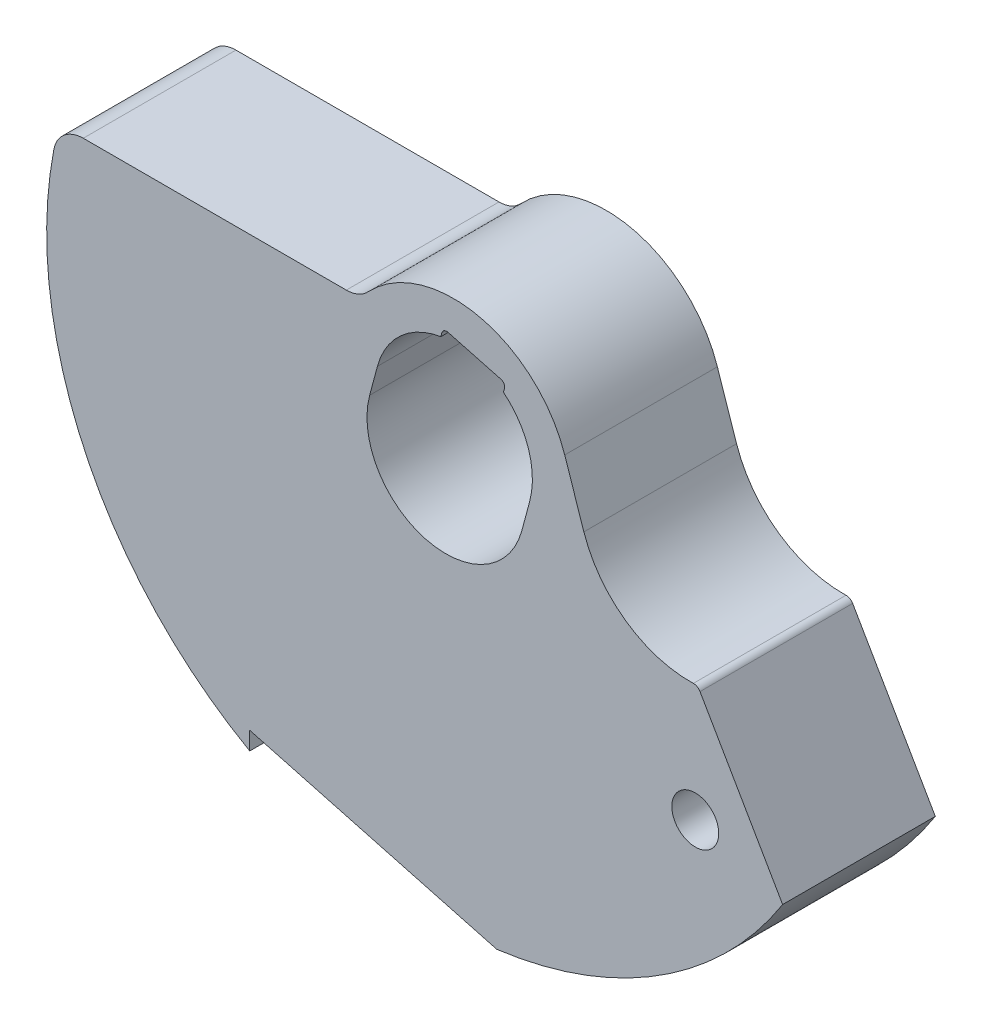
from build123d import *

# Parameters (mm, degrees)
SKETCH1_R           = 1.1938
BOSS_EXTRUDE1_DEPTH = 7.7724


with BuildPart() as part:
    # Sketch1 → Boss-Extrude1 (new body)
    with BuildSketch(Plane.XY):
        with BuildLine():
            Line((-5.065262452, 5.08), (-18.456556559, 5.08))
            ThreePointArc((-18.456556559, 5.08), (-19.426909517, 4.731155792), (-19.953034117, 3.844324324))
            ThreePointArc((-19.953034117, 3.844324324), (-18.44069754, -8.534815418), (-9.9822, -17.699098371))
            Line((-9.9822, -17.699098371), (-9.9822, -16.784328658))
            Line((-9.9822, -16.784328658), (2.593084415, -20.153865962))
            ThreePointArc((2.593084415, -20.153865962), (10.900004065, -17.149119843), (17.146958643, -10.903403565))
            Line((17.146958643, -10.903403565), (12.940315476, -3.61728387))
            ThreePointArc((12.940315476, -3.61728387), (12.796393961, -3.475289825), (12.60008731, -3.426922378))
            ThreePointArc((12.60008731, -3.426922378), (9.17217903, -2.398369889), (7.028137334, 0.467212181))
            Line((7.028137334, 0.467212181), (6.053096787, 3.371693793))
            ThreePointArc((6.053096787, 3.371693793), (1.669604011, 7.303273092), (-3.95481445, 5.560217822))
            ThreePointArc((-3.95481445, 5.560217822), (-4.460344292, 5.205196933), (-5.065262452, 5.08))
        make_face()
        with Locations((12.7, -9.398)):
            Circle(SKETCH1_R, mode=Mode.SUBTRACT)
        with BuildLine():
            Line((-3.876453526, 1.038692592), (-3.482013301, 2.510763551))
            ThreePointArc((-3.482013301, 2.510763551), (-2.298514325, 4.447599489), (-0.253578298, 5.432607064))
            Line((-0.253578298, 5.432607064), (-0.201054745, 5.628627633))
            ThreePointArc((-0.201054745, 5.628627633), (-0.082709585, 5.782858048), (0.110030452, 5.808232755))
            Line((0.110030452, 5.808232755), (2.808827211, 5.085092343))
            ThreePointArc((2.808827211, 5.085092343), (2.963057626, 4.966747183), (2.988432333, 4.774007146))
            Line((2.988432333, 4.774007146), (2.93590878, 4.577986577))
            ThreePointArc((2.93590878, 4.577986577), (4.214371541, 2.702476981), (4.270893751, 0.433378367))
            Line((4.270893751, 0.433378367), (3.876453526, -1.038692592))
            ThreePointArc((3.876453526, -1.038692592), (-1.038692592, -3.876453526), (-3.876453526, 1.038692592))
        make_face(mode=Mode.SUBTRACT)
    extrude(amount=-BOSS_EXTRUDE1_DEPTH)


solid = part.part
